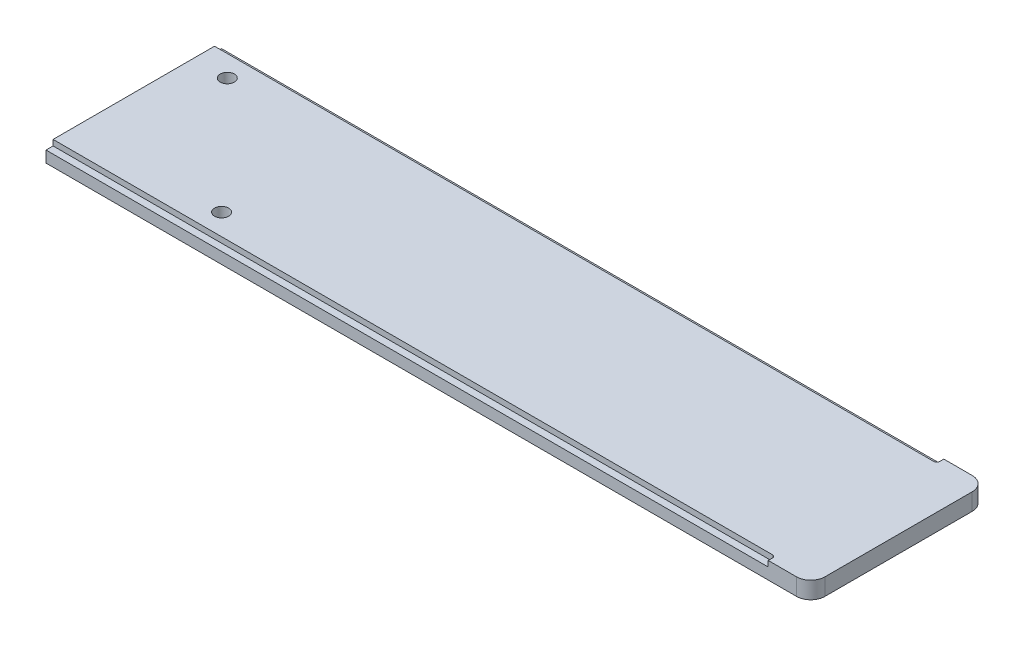
from build123d import *

# Parameters (mm, degrees)
SKETCH1_W           = 270
SKETCH1_H           = 62
BOSS_EXTRUDE1_DEPTH = 6
SKETCH2_W           = 255
SKETCH2_H           = 2.5
CUT_EXTRUDE1_DEPTH  = 2
FILLET1_R           = 1
SKETCH3_R           = 2.5
CUT_EXTRUDE2_DEPTH  = 7
FILLET2_R           = 5


with BuildPart() as part:
    # Sketch1 → Boss-Extrude1 (new body)
    with BuildSketch(Plane(origin=(0, 0, 0), x_dir=(1, 0, 0), z_dir=(0, 1, 0))):
        with Locations((135, 31)):
            Rectangle(SKETCH1_W, SKETCH1_H)
    extrude(amount=BOSS_EXTRUDE1_DEPTH)

    # Sketch2 → Cut-Extrude1 (cut)
    with BuildSketch(Plane(origin=(0, 6, 0), x_dir=(1, 0, 0), z_dir=(0, 1, 0))):
        with Locations((127.5, 60.75)):
            Rectangle(SKETCH2_W, SKETCH2_H)
        with Locations((127.5, 1.25)):
            Rectangle(SKETCH2_W, SKETCH2_H)
    extrude(amount=-CUT_EXTRUDE1_DEPTH, mode=Mode.SUBTRACT)

    # Fillet1
    fillet1_edges = [part.edges().sort_by_distance(p)[0] for p in [
        (255, 5, -59.5),
        (255, 5, -2.5),
    ]]
    fillet(fillet1_edges, radius=FILLET1_R)

    # Sketch3 → Cut-Extrude2 (cut, through all)
    with BuildSketch(Plane(origin=(0, 6, 0), x_dir=(1, 0, 0), z_dir=(0, 1, 0))):
        with Locations((12, 52)):
            Circle(SKETCH3_R)
        with Locations((52, 10)):
            Circle(SKETCH3_R)
    extrude(amount=-CUT_EXTRUDE2_DEPTH, mode=Mode.SUBTRACT)

    # Fillet2
    fillet2_edges = [part.edges().sort_by_distance(p)[0] for p in [
        (270, 3, -62),
        (270, 3, 0),
    ]]
    fillet(fillet2_edges, radius=FILLET2_R)


solid = part.part
